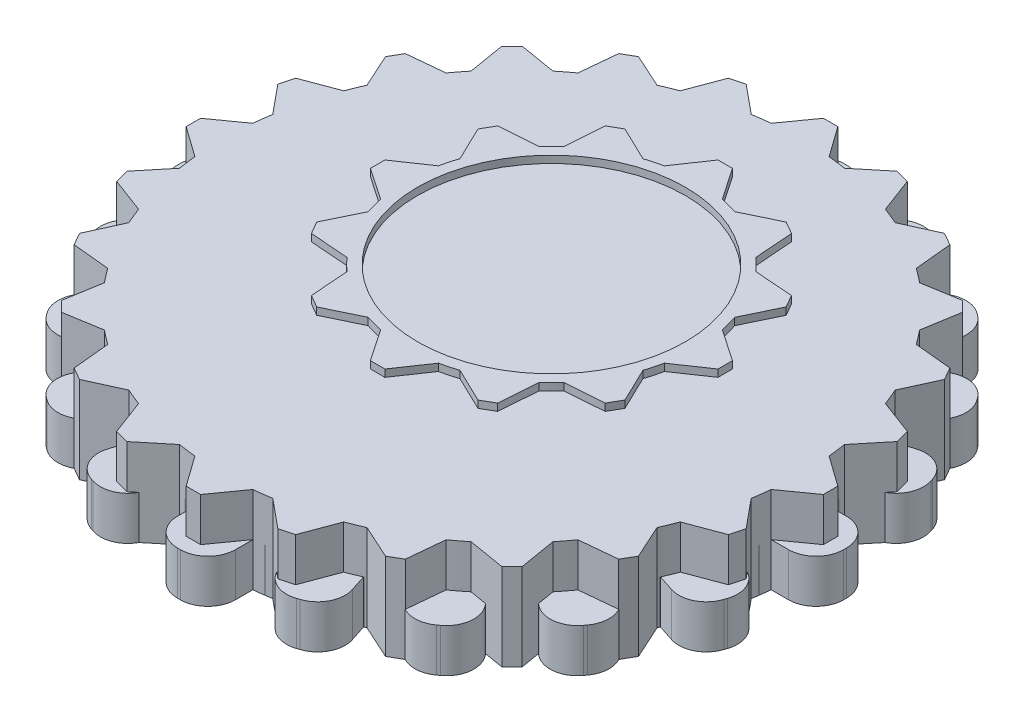
from build123d import *

# Parameters (mm, degrees)
BOSS_EXTRUDE3_DEPTH = 3
BOSS_EXTRUDE5_DEPTH = 6
BOSS_EXTRUDE6_DEPTH = 5
SKETCH6_R           = 9.25
BOSS_EXTRUDE7_DEPTH = 1.5


with BuildPart() as part:
    # Sketch2 → Boss-Extrude3 (new body)
    with BuildSketch(Plane(origin=(0, 0, 0), x_dir=(1, 0, 0), z_dir=(0, 1, 0))):
        with BuildLine():
            Line((-23, -0.1), (-23, 0.1))
            ThreePointArc((-23, 0.1), (-22.443502884, 1.443502884), (-21.1, 2))
            Line((-21.1, 2), (-19.899748742, 2))
            ThreePointArc((-19.899748742, 2), (-19.753766812, 3.128689301), (-19.543819703, 4.247247513))
            Line((-19.543819703, 4.247247513), (-20.685326483, 4.618145549))
            ThreePointArc((-20.685326483, 4.618145549), (-21.791106589, 5.56257098), (-21.905201574, 7.012285219))
            Line((-21.905201574, 7.012285219), (-21.843398175, 7.202496522))
            ThreePointArc((-21.843398175, 7.202496522), (-20.898972744, 8.308276629), (-19.449258505, 8.422371614))
            Line((-19.449258505, 8.422371614), (-18.307751725, 8.051473578))
            ThreePointArc((-18.307751725, 8.051473578), (-17.820130484, 9.079809995), (-17.274805421, 10.078744846))
            Line((-17.274805421, 10.078744846), (-18.245829086, 10.784234835))
            ThreePointArc((-18.245829086, 10.784234835), (-19.005644954, 12.02414164), (-18.666169396, 13.438159103))
            Line((-18.666169396, 13.438159103), (-18.548612345, 13.599962502))
            ThreePointArc((-18.548612345, 13.599962502), (-17.30870554, 14.35977837), (-15.894688077, 14.020302812))
            Line((-15.894688077, 14.020302812), (-14.923664412, 13.314812824))
            ThreePointArc((-14.923664412, 13.314812824), (-14.142135624, 14.142135624), (-13.314812824, 14.923664412))
            Line((-13.314812824, 14.923664412), (-14.020302812, 15.894688077))
            ThreePointArc((-14.020302812, 15.894688077), (-14.35977837, 17.30870554), (-13.599962502, 18.548612345))
            Line((-13.599962502, 18.548612345), (-13.438159103, 18.666169396))
            ThreePointArc((-13.438159103, 18.666169396), (-12.02414164, 19.005644954), (-10.784234835, 18.245829086))
            Line((-10.784234835, 18.245829086), (-10.078744846, 17.274805421))
            ThreePointArc((-10.078744846, 17.274805421), (-9.079809995, 17.820130484), (-8.051473578, 18.307751725))
            Line((-8.051473578, 18.307751725), (-8.422371614, 19.449258505))
            ThreePointArc((-8.422371614, 19.449258505), (-8.308276629, 20.898972744), (-7.202496522, 21.843398175))
            Line((-7.202496522, 21.843398175), (-7.012285219, 21.905201574))
            ThreePointArc((-7.012285219, 21.905201574), (-5.56257098, 21.791106589), (-4.618145549, 20.685326483))
            Line((-4.618145549, 20.685326483), (-4.247247513, 19.543819703))
            ThreePointArc((-4.247247513, 19.543819703), (-3.128689301, 19.753766812), (-2, 19.899748742))
            Line((-2, 19.899748742), (-2, 21.1))
            ThreePointArc((-2, 21.1), (-1.443502884, 22.443502884), (-0.1, 23))
            Line((-0.1, 23), (0.1, 23))
            ThreePointArc((0.1, 23), (1.443502884, 22.443502884), (2, 21.1))
            Line((2, 21.1), (2, 19.899748742))
            ThreePointArc((2, 19.899748742), (3.128689301, 19.753766812), (4.247247513, 19.543819703))
            Line((4.247247513, 19.543819703), (4.618145549, 20.685326483))
            ThreePointArc((4.618145549, 20.685326483), (5.56257098, 21.791106589), (7.012285219, 21.905201574))
            Line((7.012285219, 21.905201574), (7.202496522, 21.843398175))
            ThreePointArc((7.202496522, 21.843398175), (8.308276629, 20.898972744), (8.422371614, 19.449258505))
            Line((8.422371614, 19.449258505), (8.051473578, 18.307751725))
            ThreePointArc((8.051473578, 18.307751725), (9.079809995, 17.820130484), (10.078744846, 17.274805421))
            Line((10.078744846, 17.274805421), (10.784234835, 18.245829086))
            ThreePointArc((10.784234835, 18.245829086), (12.02414164, 19.005644954), (13.438159103, 18.666169396))
            Line((13.438159103, 18.666169396), (13.599962502, 18.548612345))
            ThreePointArc((13.599962502, 18.548612345), (14.35977837, 17.30870554), (14.020302812, 15.894688077))
            Line((14.020302812, 15.894688077), (13.314812824, 14.923664412))
            ThreePointArc((13.314812824, 14.923664412), (14.142135624, 14.142135624), (14.923664412, 13.314812824))
            Line((14.923664412, 13.314812824), (15.894688077, 14.020302812))
            ThreePointArc((15.894688077, 14.020302812), (17.30870554, 14.35977837), (18.548612345, 13.599962502))
            Line((18.548612345, 13.599962502), (18.666169396, 13.438159103))
            ThreePointArc((18.666169396, 13.438159103), (19.005644954, 12.02414164), (18.245829086, 10.784234835))
            Line((18.245829086, 10.784234835), (17.274805421, 10.078744846))
            ThreePointArc((17.274805421, 10.078744846), (17.820130484, 9.079809995), (18.307751725, 8.051473578))
            Line((18.307751725, 8.051473578), (19.449258505, 8.422371614))
            ThreePointArc((19.449258505, 8.422371614), (20.898972744, 8.308276629), (21.843398175, 7.202496522))
            Line((21.843398175, 7.202496522), (21.905201574, 7.012285219))
            ThreePointArc((21.905201574, 7.012285219), (21.791106589, 5.56257098), (20.685326483, 4.618145549))
            Line((20.685326483, 4.618145549), (19.543819703, 4.247247513))
            ThreePointArc((19.543819703, 4.247247513), (19.753766812, 3.128689301), (19.899748742, 2))
            Line((19.899748742, 2), (21.1, 2))
            ThreePointArc((21.1, 2), (22.443502884, 1.443502884), (23, 0.1))
            Line((23, 0.1), (23, -0.1))
            ThreePointArc((23, -0.1), (22.443502884, -1.443502884), (21.1, -2))
            Line((21.1, -2), (19.899748742, -2))
            ThreePointArc((19.899748742, -2), (19.753766812, -3.128689301), (19.543819703, -4.247247513))
            Line((19.543819703, -4.247247513), (20.685326483, -4.618145549))
            ThreePointArc((20.685326483, -4.618145549), (21.791106589, -5.56257098), (21.905201574, -7.012285219))
            Line((21.905201574, -7.012285219), (21.843398175, -7.202496522))
            ThreePointArc((21.843398175, -7.202496522), (20.898972744, -8.308276629), (19.449258505, -8.422371614))
            Line((19.449258505, -8.422371614), (18.307751725, -8.051473578))
            ThreePointArc((18.307751725, -8.051473578), (17.820130484, -9.079809995), (17.274805421, -10.078744846))
            Line((17.274805421, -10.078744846), (18.245829086, -10.784234835))
            ThreePointArc((18.245829086, -10.784234835), (19.005644954, -12.02414164), (18.666169396, -13.438159103))
            Line((18.666169396, -13.438159103), (18.548612345, -13.599962502))
            ThreePointArc((18.548612345, -13.599962502), (17.30870554, -14.35977837), (15.894688077, -14.020302812))
            Line((15.894688077, -14.020302812), (14.923664412, -13.314812824))
            ThreePointArc((14.923664412, -13.314812824), (14.142135624, -14.142135624), (13.314812824, -14.923664412))
            Line((13.314812824, -14.923664412), (14.020302812, -15.894688077))
            ThreePointArc((14.020302812, -15.894688077), (14.35977837, -17.30870554), (13.599962502, -18.548612345))
            Line((13.599962502, -18.548612345), (13.438159103, -18.666169396))
            ThreePointArc((13.438159103, -18.666169396), (12.02414164, -19.005644954), (10.784234835, -18.245829086))
            Line((10.784234835, -18.245829086), (10.078744846, -17.274805421))
            ThreePointArc((10.078744846, -17.274805421), (9.079809995, -17.820130484), (8.051473578, -18.307751725))
            Line((8.051473578, -18.307751725), (8.422371614, -19.449258505))
            ThreePointArc((8.422371614, -19.449258505), (8.308276629, -20.898972744), (7.202496522, -21.843398175))
            Line((7.202496522, -21.843398175), (7.012285219, -21.905201574))
            ThreePointArc((7.012285219, -21.905201574), (5.56257098, -21.791106589), (4.618145549, -20.685326483))
            Line((4.618145549, -20.685326483), (4.247247513, -19.543819703))
            ThreePointArc((4.247247513, -19.543819703), (3.128689301, -19.753766812), (2, -19.899748742))
            Line((2, -19.899748742), (2, -21.1))
            ThreePointArc((2, -21.1), (1.443502884, -22.443502884), (0.1, -23))
            Line((0.1, -23), (-0.1, -23))
            ThreePointArc((-0.1, -23), (-1.443502884, -22.443502884), (-2, -21.1))
            Line((-2, -21.1), (-2, -19.899748742))
            ThreePointArc((-2, -19.899748742), (-3.128689301, -19.753766812), (-4.247247513, -19.543819703))
            Line((-4.247247513, -19.543819703), (-4.618145549, -20.685326483))
            ThreePointArc((-4.618145549, -20.685326483), (-5.56257098, -21.791106589), (-7.012285219, -21.905201574))
            Line((-7.012285219, -21.905201574), (-7.202496522, -21.843398175))
            ThreePointArc((-7.202496522, -21.843398175), (-8.308276629, -20.898972744), (-8.422371614, -19.449258505))
            Line((-8.422371614, -19.449258505), (-8.051473578, -18.307751725))
            ThreePointArc((-8.051473578, -18.307751725), (-9.079809995, -17.820130484), (-10.078744846, -17.274805421))
            Line((-10.078744846, -17.274805421), (-10.784234835, -18.245829086))
            ThreePointArc((-10.784234835, -18.245829086), (-12.02414164, -19.005644954), (-13.438159103, -18.666169396))
            Line((-13.438159103, -18.666169396), (-13.599962502, -18.548612345))
            ThreePointArc((-13.599962502, -18.548612345), (-14.35977837, -17.30870554), (-14.020302812, -15.894688077))
            Line((-14.020302812, -15.894688077), (-13.314812824, -14.923664412))
            ThreePointArc((-13.314812824, -14.923664412), (-14.142135624, -14.142135624), (-14.923664412, -13.314812824))
            Line((-14.923664412, -13.314812824), (-15.894688077, -14.020302812))
            ThreePointArc((-15.894688077, -14.020302812), (-17.30870554, -14.35977837), (-18.548612345, -13.599962502))
            Line((-18.548612345, -13.599962502), (-18.666169396, -13.438159103))
            ThreePointArc((-18.666169396, -13.438159103), (-19.005644954, -12.02414164), (-18.245829086, -10.784234835))
            Line((-18.245829086, -10.784234835), (-17.274805421, -10.078744846))
            ThreePointArc((-17.274805421, -10.078744846), (-17.820130484, -9.079809995), (-18.307751725, -8.051473578))
            Line((-18.307751725, -8.051473578), (-19.449258505, -8.422371614))
            ThreePointArc((-19.449258505, -8.422371614), (-20.898972744, -8.308276629), (-21.843398175, -7.202496522))
            Line((-21.843398175, -7.202496522), (-21.905201574, -7.012285219))
            ThreePointArc((-21.905201574, -7.012285219), (-21.791106589, -5.56257098), (-20.685326483, -4.618145549))
            Line((-20.685326483, -4.618145549), (-19.543819703, -4.247247513))
            ThreePointArc((-19.543819703, -4.247247513), (-19.753766812, -3.128689301), (-19.899748742, -2))
            Line((-19.899748742, -2), (-21.1, -2))
            ThreePointArc((-21.1, -2), (-22.443502884, -1.443502884), (-23, -0.1))
        make_face()
    extrude(amount=BOSS_EXTRUDE3_DEPTH)


with BuildPart() as body_2:
    # Sketch3 → Boss-Extrude5 (new body)
    with BuildSketch(Plane(origin=(0, 0, 0), x_dir=(1, 0, 0), z_dir=(0, 1, 0))):
        with BuildLine():
            Line((-22, 0.5), (-22, 0))
            Line((-22, 0), (22, 0))
            Line((22, 0), (22, 0.5))
            Line((22, 0.5), (19.899748742, 2))
            ThreePointArc((19.899748742, 2), (19.828897227, 2.610523844), (19.739319337, 3.218582315))
            Line((19.739319337, 3.218582315), (21.379777701, 5.211056079))
            Line((21.379777701, 5.211056079), (21.120958656, 6.176981905))
            Line((21.120958656, 6.176981905), (18.704043156, 7.08228562))
            ThreePointArc((18.704043156, 7.08228562), (18.47759065, 7.653668647), (18.23368794, 8.217823563))
            Line((18.23368794, 8.217823563), (19.302558883, 10.566987298))
            Line((19.302558883, 10.566987298), (18.802558883, 11.433012702))
            Line((18.802558883, 11.433012702), (16.23368794, 11.681925179))
            ThreePointArc((16.23368794, 11.681925179), (15.867066806, 12.17522858), (15.485460842, 12.657033717))
            Line((15.485460842, 12.657033717), (15.909902577, 15.202795796))
            Line((15.909902577, 15.202795796), (15.202795796, 15.909902577))
            Line((15.202795796, 15.909902577), (12.657033717, 15.485460842))
            ThreePointArc((12.657033717, 15.485460842), (12.17522858, 15.867066806), (11.681925179, 16.23368794))
            Line((11.681925179, 16.23368794), (11.433012702, 18.802558883))
            Line((11.433012702, 18.802558883), (10.566987298, 19.302558883))
            Line((10.566987298, 19.302558883), (8.217823563, 18.23368794))
            ThreePointArc((8.217823563, 18.23368794), (7.653668647, 18.47759065), (7.08228562, 18.704043156))
            Line((7.08228562, 18.704043156), (6.176981905, 21.120958656))
            Line((6.176981905, 21.120958656), (5.211056079, 21.379777701))
            Line((5.211056079, 21.379777701), (3.218582315, 19.739319337))
            ThreePointArc((3.218582315, 19.739319337), (2.610523844, 19.828897227), (2, 19.899748742))
            Line((2, 19.899748742), (0.5, 22))
            Line((0.5, 22), (-0.5, 22))
            Line((-0.5, 22), (-2, 19.899748742))
            ThreePointArc((-2, 19.899748742), (-2.610523844, 19.828897227), (-3.218582315, 19.739319337))
            Line((-3.218582315, 19.739319337), (-5.211056079, 21.379777701))
            Line((-5.211056079, 21.379777701), (-6.176981905, 21.120958656))
            Line((-6.176981905, 21.120958656), (-7.08228562, 18.704043156))
            ThreePointArc((-7.08228562, 18.704043156), (-7.653668647, 18.47759065), (-8.217823563, 18.23368794))
            Line((-8.217823563, 18.23368794), (-10.566987298, 19.302558883))
            Line((-10.566987298, 19.302558883), (-11.433012702, 18.802558883))
            Line((-11.433012702, 18.802558883), (-11.681925179, 16.23368794))
            ThreePointArc((-11.681925179, 16.23368794), (-12.17522858, 15.867066806), (-12.657033717, 15.485460842))
            Line((-12.657033717, 15.485460842), (-15.202795796, 15.909902577))
            Line((-15.202795796, 15.909902577), (-15.909902577, 15.202795796))
            Line((-15.909902577, 15.202795796), (-15.485460842, 12.657033717))
            ThreePointArc((-15.485460842, 12.657033717), (-15.867066806, 12.17522858), (-16.23368794, 11.681925179))
            Line((-16.23368794, 11.681925179), (-18.802558883, 11.433012702))
            Line((-18.802558883, 11.433012702), (-19.302558883, 10.566987298))
            Line((-19.302558883, 10.566987298), (-18.23368794, 8.217823563))
            ThreePointArc((-18.23368794, 8.217823563), (-18.47759065, 7.653668647), (-18.704043156, 7.08228562))
            Line((-18.704043156, 7.08228562), (-21.120958656, 6.176981905))
            Line((-21.120958656, 6.176981905), (-21.379777701, 5.211056079))
            Line((-21.379777701, 5.211056079), (-19.739319337, 3.218582315))
            ThreePointArc((-19.739319337, 3.218582315), (-19.828897227, 2.610523844), (-19.899748742, 2))
            Line((-19.899748742, 2), (-22, 0.5))
        make_face()
        with BuildLine():
            Line((22, 0), (-22, 0))
            Line((-22, 0), (-22, -0.5))
            Line((-22, -0.5), (-19.899748742, -2))
            ThreePointArc((-19.899748742, -2), (-19.828897227, -2.610523844), (-19.739319337, -3.218582315))
            Line((-19.739319337, -3.218582315), (-21.379777701, -5.211056079))
            Line((-21.379777701, -5.211056079), (-21.120958656, -6.176981905))
            Line((-21.120958656, -6.176981905), (-18.704043156, -7.08228562))
            ThreePointArc((-18.704043156, -7.08228562), (-18.47759065, -7.653668647), (-18.23368794, -8.217823563))
            Line((-18.23368794, -8.217823563), (-19.302558883, -10.566987298))
            Line((-19.302558883, -10.566987298), (-18.802558883, -11.433012702))
            Line((-18.802558883, -11.433012702), (-16.23368794, -11.681925179))
            ThreePointArc((-16.23368794, -11.681925179), (-15.867066806, -12.17522858), (-15.485460842, -12.657033717))
            Line((-15.485460842, -12.657033717), (-15.909902577, -15.202795796))
            Line((-15.909902577, -15.202795796), (-15.202795796, -15.909902577))
            Line((-15.202795796, -15.909902577), (-12.657033717, -15.485460842))
            ThreePointArc((-12.657033717, -15.485460842), (-12.17522858, -15.867066806), (-11.681925179, -16.23368794))
            Line((-11.681925179, -16.23368794), (-11.433012702, -18.802558883))
            Line((-11.433012702, -18.802558883), (-10.566987298, -19.302558883))
            Line((-10.566987298, -19.302558883), (-8.217823563, -18.23368794))
            ThreePointArc((-8.217823563, -18.23368794), (-7.653668647, -18.47759065), (-7.08228562, -18.704043156))
            Line((-7.08228562, -18.704043156), (-6.176981905, -21.120958656))
            Line((-6.176981905, -21.120958656), (-5.211056079, -21.379777701))
            Line((-5.211056079, -21.379777701), (-3.218582315, -19.739319337))
            ThreePointArc((-3.218582315, -19.739319337), (-2.610523844, -19.828897227), (-2, -19.899748742))
            Line((-2, -19.899748742), (-0.5, -22))
            Line((-0.5, -22), (0.5, -22))
            Line((0.5, -22), (2, -19.899748742))
            ThreePointArc((2, -19.899748742), (2.610523844, -19.828897227), (3.218582315, -19.739319337))
            Line((3.218582315, -19.739319337), (5.211056079, -21.379777701))
            Line((5.211056079, -21.379777701), (6.176981905, -21.120958656))
            Line((6.176981905, -21.120958656), (7.08228562, -18.704043156))
            ThreePointArc((7.08228562, -18.704043156), (7.653668647, -18.47759065), (8.217823563, -18.23368794))
            Line((8.217823563, -18.23368794), (10.566987298, -19.302558883))
            Line((10.566987298, -19.302558883), (11.433012702, -18.802558883))
            Line((11.433012702, -18.802558883), (11.681925179, -16.23368794))
            ThreePointArc((11.681925179, -16.23368794), (12.17522858, -15.867066806), (12.657033717, -15.485460842))
            Line((12.657033717, -15.485460842), (15.202795796, -15.909902577))
            Line((15.202795796, -15.909902577), (15.909902577, -15.202795796))
            Line((15.909902577, -15.202795796), (15.485460842, -12.657033717))
            ThreePointArc((15.485460842, -12.657033717), (15.867066806, -12.17522858), (16.23368794, -11.681925179))
            Line((16.23368794, -11.681925179), (18.802558883, -11.433012702))
            Line((18.802558883, -11.433012702), (19.302558883, -10.566987298))
            Line((19.302558883, -10.566987298), (18.23368794, -8.217823563))
            ThreePointArc((18.23368794, -8.217823563), (18.47759065, -7.653668647), (18.704043156, -7.08228562))
            Line((18.704043156, -7.08228562), (21.120958656, -6.176981905))
            Line((21.120958656, -6.176981905), (21.379777701, -5.211056079))
            Line((21.379777701, -5.211056079), (19.739319337, -3.218582315))
            ThreePointArc((19.739319337, -3.218582315), (19.828897227, -2.610523844), (19.899748742, -2))
            Line((19.899748742, -2), (22, -0.5))
            Line((22, -0.5), (22, 0))
        make_face()
    extrude(amount=BOSS_EXTRUDE5_DEPTH)


with BuildPart() as body_3:
    # Sketch1 → Boss-Extrude6 (new body)
    with BuildSketch(Plane(origin=(0, 0, 0), x_dir=(1, 0, 0), z_dir=(0, 1, 0))):
        with BuildLine():
            Line((-1.142396869, 15.366895677), (-0.142396869, 15.366895677))
            Line((-0.142396869, 15.366895677), (1.357603131, 13.164854648))
            ThreePointArc((1.357603131, 13.164854648), (1.945793582, 13.026153939), (2.524531809, 12.852177051))
            Line((2.524531809, 12.852177051), (4.924590429, 14.009200522))
            Line((4.924590429, 14.009200522), (5.790615833, 13.509200522))
            Line((5.790615833, 13.509200522), (5.988633424, 10.852177051))
            ThreePointArc((5.988633424, 10.852177051), (6.428670943, 10.437963488), (6.842884505, 9.99792597))
            Line((6.842884505, 9.99792597), (9.499907976, 9.799908378))
            Line((9.499907976, 9.799908378), (9.999907976, 8.933882975))
            Line((9.999907976, 8.933882975), (8.842884505, 6.533824355))
            ThreePointArc((8.842884505, 6.533824355), (9.016861394, 5.955086128), (9.155562102, 5.366895677))
            Line((9.155562102, 5.366895677), (11.357603131, 3.866895677))
            Line((11.357603131, 3.866895677), (11.357603131, 2.866895677))
            Line((11.357603131, 2.866895677), (9.155562102, 1.366895677))
            ThreePointArc((9.155562102, 1.366895677), (9.016861394, 0.778705226), (8.842884505, 0.199966999))
            Line((8.842884505, 0.199966999), (9.999907976, -2.200091622))
            Line((9.999907976, -2.200091622), (9.499907976, -3.066117025))
            Line((9.499907976, -3.066117025), (6.842884505, -3.264134617))
            ThreePointArc((6.842884505, -3.264134617), (6.428670943, -3.704172135), (5.988633424, -4.118385698))
            Line((5.988633424, -4.118385698), (5.790615833, -6.775409169))
            Line((5.790615833, -6.775409169), (4.924590429, -7.275409169))
            Line((4.924590429, -7.275409169), (2.524531809, -6.118385698))
            ThreePointArc((2.524531809, -6.118385698), (1.945793582, -6.292362586), (1.357603131, -6.431063295))
            Line((1.357603131, -6.431063295), (-0.142396869, -8.633104323))
            Line((-0.142396869, -8.633104323), (-1.142396869, -8.633104323))
            Line((-1.142396869, -8.633104323), (-2.642396869, -6.431063295))
            ThreePointArc((-2.642396869, -6.431063295), (-3.23058732, -6.292362586), (-3.809325547, -6.118385698))
            Line((-3.809325547, -6.118385698), (-6.209384167, -7.275409169))
            Line((-6.209384167, -7.275409169), (-7.075409571, -6.775409169))
            Line((-7.075409571, -6.775409169), (-7.273427162, -4.118385698))
            ThreePointArc((-7.273427162, -4.118385698), (-7.713464681, -3.704172135), (-8.127678243, -3.264134617))
            Line((-8.127678243, -3.264134617), (-10.784701714, -3.066117025))
            Line((-10.784701714, -3.066117025), (-11.284701714, -2.200091622))
            Line((-11.284701714, -2.200091622), (-10.127678243, 0.199966999))
            ThreePointArc((-10.127678243, 0.199966999), (-10.301655132, 0.778705226), (-10.44035584, 1.366895677))
            Line((-10.44035584, 1.366895677), (-12.642396869, 2.866895677))
            Line((-12.642396869, 2.866895677), (-12.642396869, 3.866895677))
            Line((-12.642396869, 3.866895677), (-10.44035584, 5.366895677))
            ThreePointArc((-10.44035584, 5.366895677), (-10.301655132, 5.955086128), (-10.127678243, 6.533824355))
            Line((-10.127678243, 6.533824355), (-11.284701714, 8.933882975))
            Line((-11.284701714, 8.933882975), (-10.784701714, 9.799908378))
            Line((-10.784701714, 9.799908378), (-8.127678243, 9.99792597))
            ThreePointArc((-8.127678243, 9.99792597), (-7.713464681, 10.437963488), (-7.273427162, 10.852177051))
            Line((-7.273427162, 10.852177051), (-7.075409571, 13.509200522))
            Line((-7.075409571, 13.509200522), (-6.209384167, 14.009200522))
            Line((-6.209384167, 14.009200522), (-3.809325547, 12.852177051))
            ThreePointArc((-3.809325547, 12.852177051), (-3.23058732, 13.026153939), (-2.642396869, 13.164854648))
            Line((-2.642396869, 13.164854648), (-1.142396869, 15.366895677))
        make_face()
        with BuildLine():
            Line((-2.642396869, 4.866895677), (1.357603131, 4.866895677))
            ThreePointArc((1.357603131, 4.866895677), (1.857603131, 3.366895677), (1.357603131, 1.866895677))
            Line((1.357603131, 1.866895677), (-2.642396869, 1.866895677))
            ThreePointArc((-2.642396869, 1.866895677), (-3.142396869, 3.366895677), (-2.642396869, 4.866895677))
        make_face(mode=Mode.SUBTRACT)
    extrude(amount=BOSS_EXTRUDE6_DEPTH)

    # Sketch6 → Boss-Extrude7 (add)
    with BuildSketch(Plane(origin=(0, 5, 0), x_dir=(1, 0, 0), z_dir=(0, 1, 0))):
        with BuildLine():
            Line((-1.142396869, 15.366895677), (-2.642396869, 13.164854648))
            ThreePointArc((-2.642396869, 13.164854648), (-3.23058732, 13.026153939), (-3.809325547, 12.852177051))
            Line((-3.809325547, 12.852177051), (-6.209384167, 14.009200522))
            Line((-6.209384167, 14.009200522), (-7.075409571, 13.509200522))
            Line((-7.075409571, 13.509200522), (-7.273427162, 10.852177051))
            ThreePointArc((-7.273427162, 10.852177051), (-7.713464681, 10.437963488), (-8.127678243, 9.99792597))
            Line((-8.127678243, 9.99792597), (-10.784701714, 9.799908378))
            Line((-10.784701714, 9.799908378), (-11.284701714, 8.933882975))
            Line((-11.284701714, 8.933882975), (-10.127678243, 6.533824355))
            ThreePointArc((-10.127678243, 6.533824355), (-10.301655132, 5.955086128), (-10.44035584, 5.366895677))
            Line((-10.44035584, 5.366895677), (-12.642396869, 3.866895677))
            Line((-12.642396869, 3.866895677), (-12.642396869, 2.866895677))
            Line((-12.642396869, 2.866895677), (-10.44035584, 1.366895677))
            ThreePointArc((-10.44035584, 1.366895677), (-10.301655132, 0.778705226), (-10.127678243, 0.199966999))
            Line((-10.127678243, 0.199966999), (-11.284701714, -2.200091622))
            Line((-11.284701714, -2.200091622), (-10.784701714, -3.066117025))
            Line((-10.784701714, -3.066117025), (-8.127678243, -3.264134617))
            ThreePointArc((-8.127678243, -3.264134617), (-7.713464681, -3.704172135), (-7.273427162, -4.118385698))
            Line((-7.273427162, -4.118385698), (-7.075409571, -6.775409169))
            Line((-7.075409571, -6.775409169), (-6.209384167, -7.275409169))
            Line((-6.209384167, -7.275409169), (-3.809325547, -6.118385698))
            ThreePointArc((-3.809325547, -6.118385698), (-3.23058732, -6.292362586), (-2.642396869, -6.431063295))
            Line((-2.642396869, -6.431063295), (-1.142396869, -8.633104323))
            Line((-1.142396869, -8.633104323), (-0.142396869, -8.633104323))
            Line((-0.142396869, -8.633104323), (1.357603131, -6.431063295))
            ThreePointArc((1.357603131, -6.431063295), (1.945793582, -6.292362586), (2.524531809, -6.118385698))
            Line((2.524531809, -6.118385698), (4.924590429, -7.275409169))
            Line((4.924590429, -7.275409169), (5.790615833, -6.775409169))
            Line((5.790615833, -6.775409169), (5.988633424, -4.118385698))
            ThreePointArc((5.988633424, -4.118385698), (6.428670943, -3.704172135), (6.842884505, -3.264134617))
            Line((6.842884505, -3.264134617), (9.499907976, -3.066117025))
            Line((9.499907976, -3.066117025), (9.999907976, -2.200091622))
            Line((9.999907976, -2.200091622), (8.842884505, 0.199966999))
            ThreePointArc((8.842884505, 0.199966999), (9.016861394, 0.778705226), (9.155562102, 1.366895677))
            Line((9.155562102, 1.366895677), (11.357603131, 2.866895677))
            Line((11.357603131, 2.866895677), (11.357603131, 3.866895677))
            Line((11.357603131, 3.866895677), (9.155562102, 5.366895677))
            ThreePointArc((9.155562102, 5.366895677), (9.016861394, 5.955086128), (8.842884505, 6.533824355))
            Line((8.842884505, 6.533824355), (9.999907976, 8.933882975))
            Line((9.999907976, 8.933882975), (9.499907976, 9.799908378))
            Line((9.499907976, 9.799908378), (6.842884505, 9.99792597))
            ThreePointArc((6.842884505, 9.99792597), (6.428670943, 10.437963488), (5.988633424, 10.852177051))
            Line((5.988633424, 10.852177051), (5.790615833, 13.509200522))
            Line((5.790615833, 13.509200522), (4.924590429, 14.009200522))
            Line((4.924590429, 14.009200522), (2.524531809, 12.852177051))
            ThreePointArc((2.524531809, 12.852177051), (1.945793582, 13.026153939), (1.357603131, 13.164854648))
            Line((1.357603131, 13.164854648), (-0.142396869, 15.366895677))
            Line((-0.142396869, 15.366895677), (-1.142396869, 15.366895677))
        make_face()
        with Locations((-0.642396869, 3.366895677)):
            Circle(SKETCH6_R, mode=Mode.SUBTRACT)
    extrude(amount=BOSS_EXTRUDE7_DEPTH)


solid = Compound([part.part, body_2.part, body_3.part])
